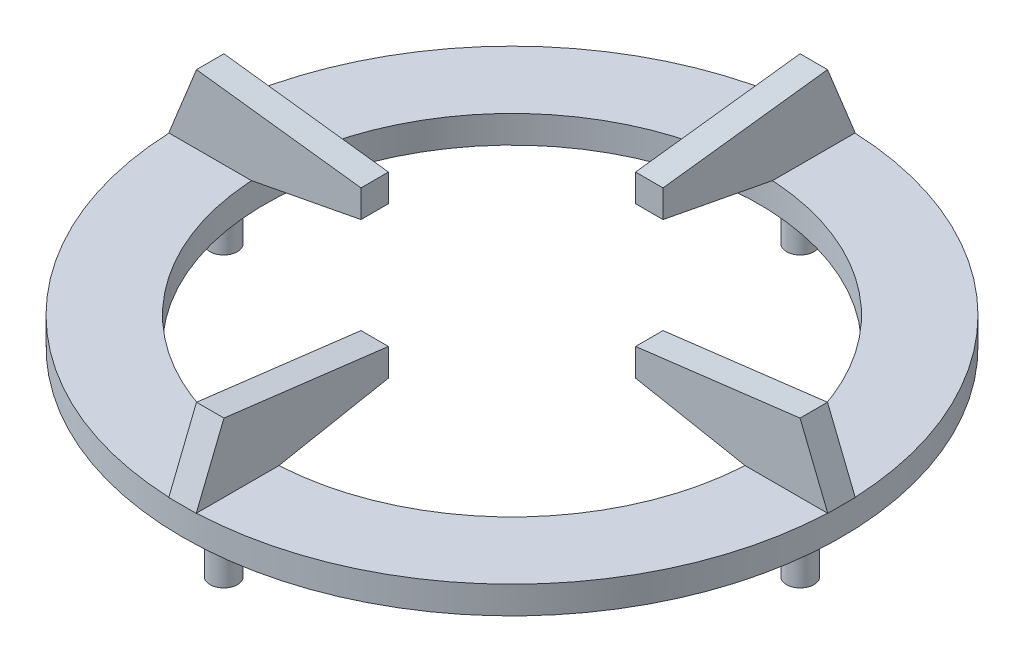
from build123d import *

# Parameters (mm, degrees)
SKETCH1_R                = 24
SKETCH1_R_2              = 18
BOSS_EXTRUDE1_DEPTH      = 2
BOSS_EXTRUDE2_DEPTH      = 1
BOSS_EXTRUDE2_DEPTH_BACK = 1
BOSS_EXTRUDE3_DEPTH      = 1
BOSS_EXTRUDE3_DEPTH_BACK = 1
SKETCH5_R                = 1
BOSS_EXTRUDE4_DEPTH      = 4


with BuildPart() as part:
    # Sketch1 → Boss-Extrude1 (new body)
    with BuildSketch(Plane(origin=(0, 0, 0), x_dir=(1, 0, 0), z_dir=(0, 1, 0))):
        Circle(SKETCH1_R)
        Circle(SKETCH1_R_2, mode=Mode.SUBTRACT)
    extrude(amount=BOSS_EXTRUDE1_DEPTH)

    # Sketch3 → Boss-Extrude2 (add, two sides: drawn at the far end of the back side and taken through both)
    with BuildSketch(Plane.XY.offset(-BOSS_EXTRUDE2_DEPTH_BACK)):
        Polygon((24, 2), (21.979868871, 7), (10, 5.529057061), (10, 3.529057061), (18, 2), align=None)
        Polygon((-10, 3.529057061), (-18, 2), (-24, 2), (-21.979868871, 7), (-10, 5.529057061), align=None)
    extrude(amount=BOSS_EXTRUDE2_DEPTH + BOSS_EXTRUDE2_DEPTH_BACK)

    # Sketch4 → Boss-Extrude3 (add, two sides: drawn at the far end of the back side and taken through both)
    with BuildSketch(Plane(origin=(0, 0, 0), x_dir=(0, 0, -1), z_dir=(1, 0, 0)).offset(-BOSS_EXTRUDE3_DEPTH_BACK)):
        Polygon((24, 2), (21.979868871, 7), (10, 5.529057061), (10, 3.529057061), (18, 2), align=None)
        Polygon((-10, 3.529057061), (-18, 2), (-24, 2), (-21.979868871, 7), (-10, 5.529057061), align=None)
    extrude(amount=BOSS_EXTRUDE3_DEPTH + BOSS_EXTRUDE3_DEPTH_BACK)

    # Sketch5 → Boss-Extrude4 (add)
    with BuildSketch(Plane.XZ):
        with Locations((21, 0)):
            Circle(SKETCH5_R)
        with Locations((0, 21)):
            Circle(SKETCH5_R)
        with Locations((0, -21)):
            Circle(SKETCH5_R)
        with Locations((-21, 0)):
            Circle(SKETCH5_R)
    extrude(amount=BOSS_EXTRUDE4_DEPTH)


solid = part.part
